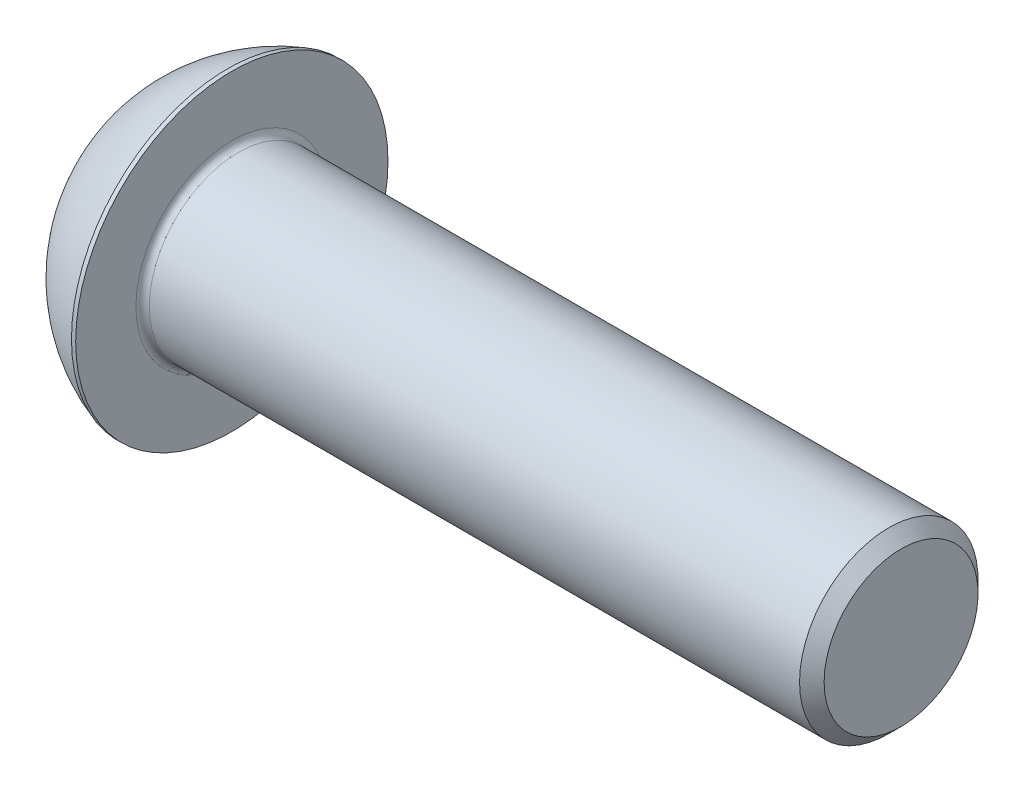
from build123d import *

# Parameters (mm, degrees)
FILLET1_R   = 0.6
HEX_2_DEPTH = 3.0988


with BuildPart() as part:
    # BodySke → BaseBody (revolve)
    with BuildSketch(Plane.XY):
        with BuildLine():
            Line((68.8, 0), (68.8, 6.8985))
            Line((68.8, 6.8985), (67.6985, 8))
            Line((67.6985, 8), (8.8, 8))
            Line((8.8, 8), (8.8, 14))
            Line((8.8, 14), (8.42, 14))
            ThreePointArc((8.42, 14), (3.53447189, 11.312563812), (0, 7))
            Line((0, 7), (0, 0))
            Line((0, 0), (68.8, 0))
        make_face()
    revolve(axis=Axis((0, 0, 0), (1, 0, 0)))

    # Fillet1
    fillet1_edges = [part.edges().sort_by_distance(p)[0] for p in [
        (8.8, -8, 0),
    ]]
    fillet(fillet1_edges, radius=FILLET1_R)

    # Sketch2 → PreBroach (revolve, cut)
    with BuildSketch(Plane.XY):
        Polygon((0, 5), (3.0988, 5), (5.985551346, 0), (0, 0), align=None)
    revolve(axis=Axis((0, 0, 0), (1, 0, 0)), mode=Mode.SUBTRACT)

    # Sketch3 → Hex 2 (cut)
    with BuildSketch(Plane(origin=(0, 0, 0), x_dir=(0, 0, -1), z_dir=(1, 0, 0))):
        Polygon((-5, -2.886751346), (-5, 2.886751346), (0, 5.773502692), (5, 2.886751346), (5, -2.886751346), (0, -5.773502692), align=None)
    extrude(amount=HEX_2_DEPTH, mode=Mode.SUBTRACT)


solid = part.part
